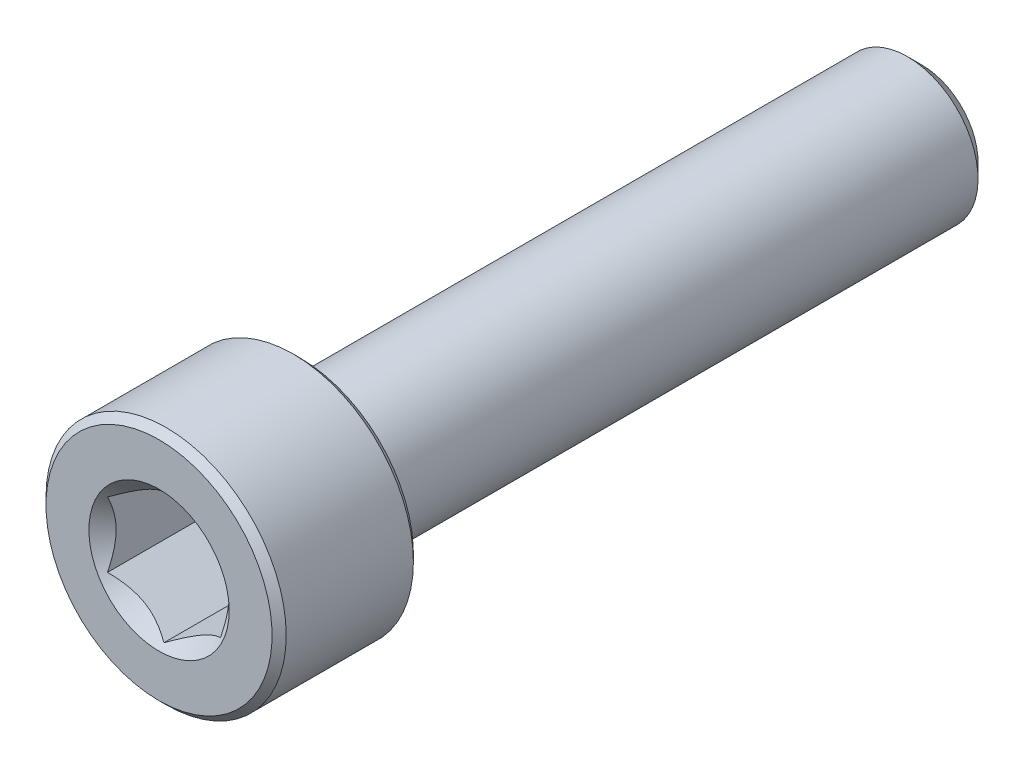
from build123d import *

# Parameters (mm, degrees)
CUT_EXTRUDE1_DEPTH = 4
SKETCH4_R          = 2.482606158
CUT_EXTRUDE2_DEPTH = 4
CUT_EXTRUDE2_DRAFT = -45


with BuildPart() as part:
    # Sketch2 → Revolve1 (revolve)
    with BuildSketch(Plane(origin=(0, 0, 0), x_dir=(0, 0, -1), z_dir=(1, 0, 0))):
        with BuildLine():
            Line((-13.5, 0), (-13.5, 4))
            Line((-13.5, 4), (-13.25, 4.25))
            Line((-13.25, 4.25), (-8.75, 4.25))
            Line((-8.75, 4.25), (-8.5, 4))
            Line((-8.5, 4), (-8.5, 2.75))
            ThreePointArc((-8.5, 2.75), (-8.426776695, 2.573223305), (-8.25, 2.5))
            Line((-8.25, 2.5), (12.980384758, 2.5))
            Line((12.980384758, 2.5), (13.5, 1.980384758))
            Line((13.5, 1.980384758), (13.5, 0))
            Line((13.5, 0), (-13.5, 0))
        make_face()
    revolve(axis=Axis((0, 0, -13.5), (0, 0, 1)))

    # Sketch3 → Cut-Extrude1 (cut)
    with BuildSketch(Plane.XY.offset(13.5)):
        Polygon((2, -1.154700538), (2, 1.154700538), (0, 2.309401077), (-2, 1.154700538), (-2, -1.154700538), (0, -2.309401077), align=None)
    extrude(amount=-CUT_EXTRUDE1_DEPTH, mode=Mode.SUBTRACT)


with BuildPart() as cut_extrude2_tool:
    # Sketch4 → Cut-Extrude2 (with draft: the straight prism first)
    with BuildSketch(Plane.XY.offset(13.5)):
        Circle(SKETCH4_R)
    extrude(amount=-CUT_EXTRUDE2_DEPTH)
    # Cut-Extrude2: the draft: its side faces are tilted about the plane it starts from
    cut_extrude2_sides = [cut_extrude2_tool.faces().sort_by_distance(p)[0] for p in [
        (-2.482606158, 0, 11.5),
    ]]
    draft(cut_extrude2_sides, Plane.XY.offset(13.5), CUT_EXTRUDE2_DRAFT)


with BuildPart() as part_1:
    add(part.part)

    # Cut-Extrude2: cut by cut_extrude2_tool
    add(cut_extrude2_tool.part, mode=Mode.SUBTRACT)


solid = part_1.part
